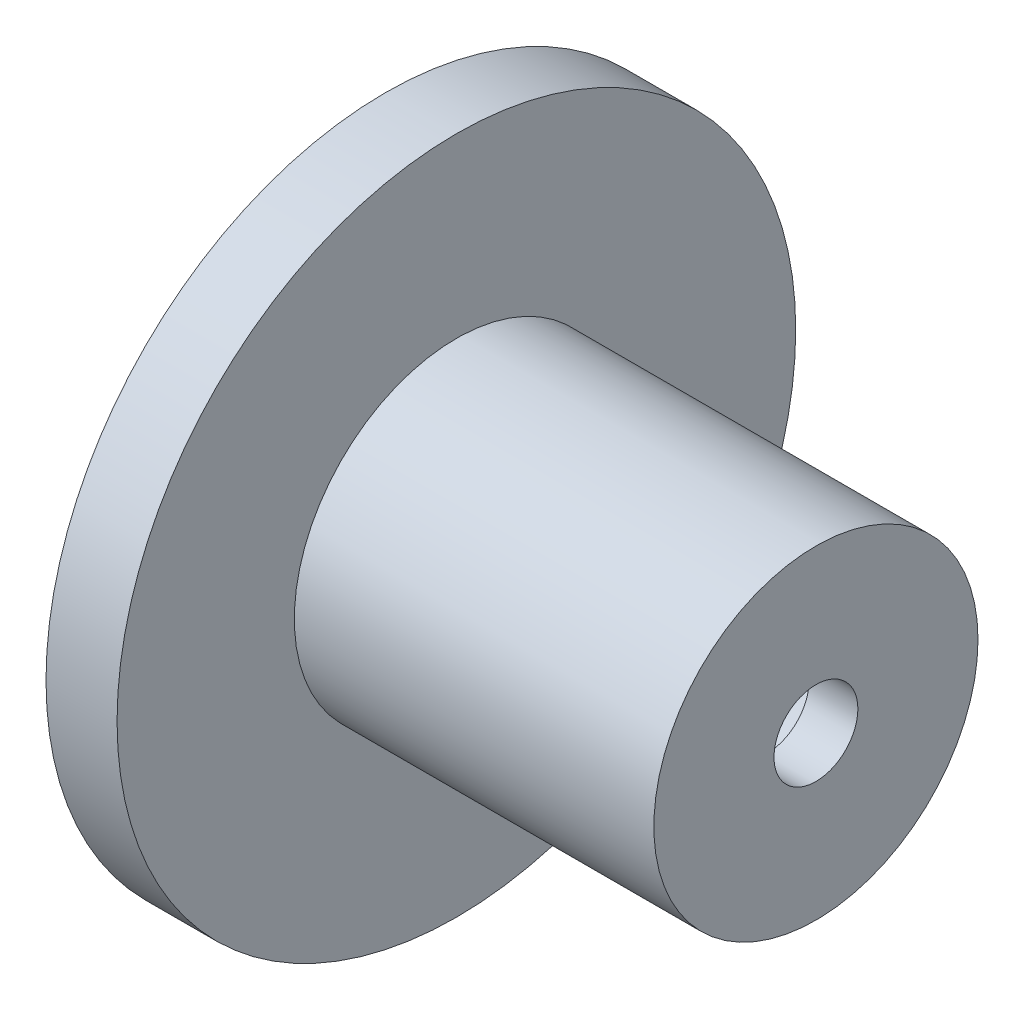
from build123d import *


with BuildPart() as part:
    # Sketch1 → Revolve1 (revolve)
    with BuildSketch(Plane.XY):
        Polygon((38.670605563, 0), (36.237312605, 0), (36.237312605, 3.47429672), (13.408906872, 3.406172878), (13.408906872, 5.994605406), (17.18221751, 5.994605406), (17.18221751, 14.840865577), (20.728109844, 14.840865577), (20.728109844, 5.994605406), (38.670605563, 5.994605406), align=None)
    revolve(axis=Axis((34.237312605, -2.093827122, 0), (-1, 0, 0)))


solid = part.part
